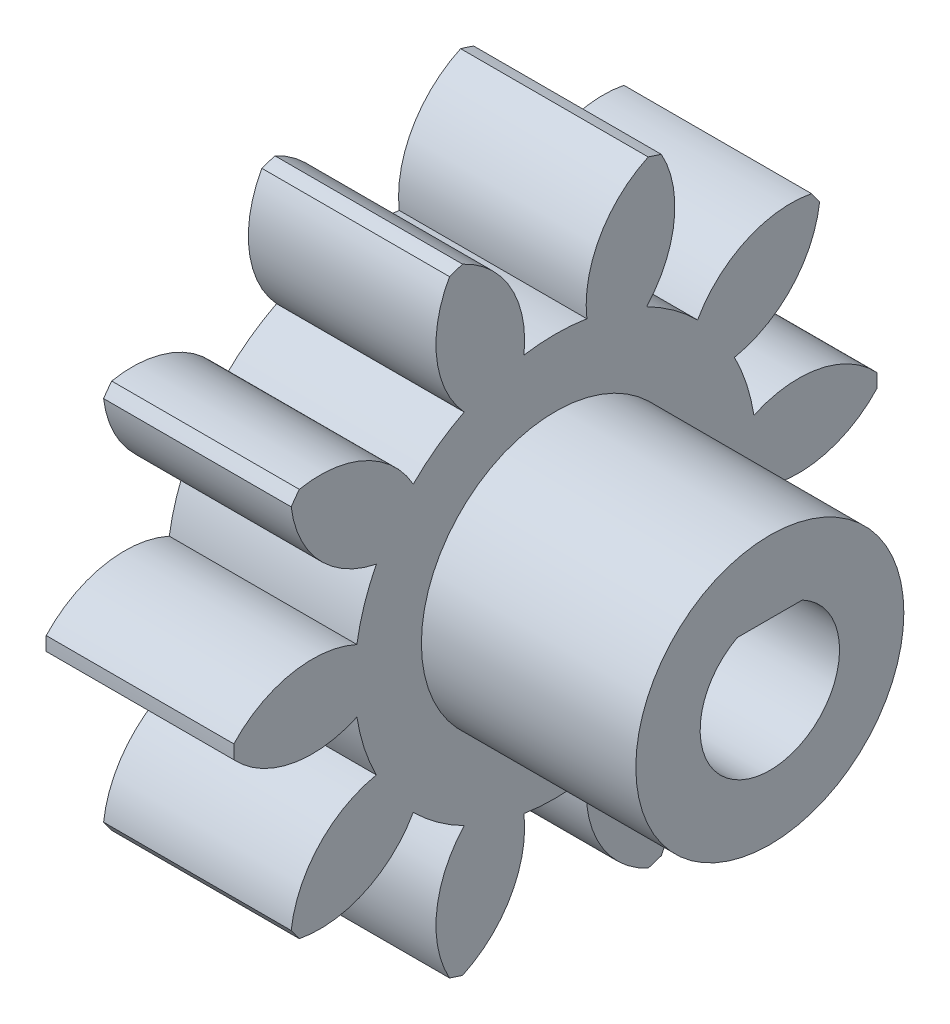
from build123d import *

# Parameters (mm, degrees)
BASPROSKE_W         = 15
BASPROSKE_H         = 12
TOOTHCUT_DEPTH      = 23.649503306
TEETHCUTS_COUNT     = 10
TEETHCUTS_ANGLE     = 324
BORSKE_R            = 0.45
BORE_DEPTH          = 50.0000508
SKETCH1_R           = 0.45
CUT_EXTRUDE1_DEPTH  = 15
CUT_EXTRUDE2_DEPTH  = 8
SKETCH6_R           = 5
BOSS_EXTRUDE1_DEPTH = 8


with BuildPart() as part:
    # BasProSke → Base-Revolve (revolve)
    with BuildSketch(Plane(origin=(0, 0, 0), x_dir=(1, 0, 0), z_dir=(0, 1, 0)), mode=Mode.PRIVATE) as base_revolve_sk:
        with Locations((7.5, 6)):
            Rectangle(BASPROSKE_W, BASPROSKE_H)
    revolve(base_revolve_sk.sketch.rotate(Axis((-10, 0, 0), (1, 0, 0)), 180), axis=Axis((-10, 0, 0), (1, 0, 0)))

    # TooCutSke → ToothCut (cut, through all)
    with BuildSketch(Plane(origin=(0, 0, 0), x_dir=(0, 0, -1), z_dir=(1, 0, 0))):
        with BuildLine():
            ThreePointArc((1.173662691, 7.406586048), (0, 7.499), (-1.173662691, 7.406586048))
            ThreePointArc((-1.173662691, 7.406586048), (-1.668191438, 9.834565786), (-3.497907776, 11.50542856))
            ThreePointArc((-3.497907776, 11.50542856), (0, 12.0254), (3.497907776, 11.50542856))
            ThreePointArc((3.497907776, 11.50542856), (1.668191438, 9.834565786), (1.173662691, 7.406586048))
        make_face()
    toothcut = extrude(amount=TOOTHCUT_DEPTH, mode=Mode.SUBTRACT)

    # TeethCuts: ToothCut ×10 about axis
    teethcuts_axis = Axis((-10, 0, 0), (1, 0, 0))
    for i in range(1, TEETHCUTS_COUNT):
        add(toothcut.rotate(teethcuts_axis, i * TEETHCUTS_ANGLE / (TEETHCUTS_COUNT - 1)), mode=Mode.SUBTRACT)

    # BorSke → Bore (cut, symmetric)
    with BuildSketch(Plane(origin=(0, 0, 0), x_dir=(0, 0, -1), z_dir=(1, 0, 0))):
        with Locations(Location((0, 0, 0), (0, 0, 180))):
            Circle(BORSKE_R)
    extrude(amount=BORE_DEPTH, both=True, mode=Mode.SUBTRACT)

    # Sketch1 → Cut-Extrude1 (cut)
    with BuildSketch(Plane.ZY):
        with BuildLine():
            Line((1.212435565, 2.3), (-1.212435565, 2.3))
            ThreePointArc((-1.212435565, 2.3), (-1.343068786, -2.226244873), (2.6, 0))
            ThreePointArc((2.6, 0), (2.226244873, 1.343068786), (1.212435565, 2.3))
        make_face()
        Circle(SKETCH1_R, mode=Mode.SUBTRACT)
    extrude(amount=-CUT_EXTRUDE1_DEPTH, mode=Mode.SUBTRACT)

    # Sketch5 → Cut-Extrude2 (cut)
    with BuildSketch(Plane.ZY):
        with BuildLine():
            ThreePointArc((-7.406763642, 1.172541409), (-9.849931218, 1.456299749), (-11.997250213, 0.256880001))
            ThreePointArc((-11.997250213, 0.256880001), (-12, 0), (-11.997250213, -0.256880001))
            ThreePointArc((-11.997250213, -0.256880001), (-9.849931218, -1.456299749), (-7.406763642, -1.172541409))
            ThreePointArc((-7.406763642, -1.172541409), (-7.131972816, -2.317318441), (-6.681400207, -3.404980509))
            ThreePointArc((-6.681400207, -3.404980509), (-8.824753264, -4.61147306), (-9.856969584, -6.843986457))
            ThreePointArc((-9.856969584, -6.843986457), (-9.708203932, -7.053423028), (-9.554989032, -7.259627029))
            ThreePointArc((-9.554989032, -7.259627029), (-7.112770233, -6.967815552), (-5.302995112, -5.302192362))
            ThreePointArc((-5.302995112, -5.302192362), (-4.407801607, -6.066818441), (-3.403968986, -6.681915604))
            ThreePointArc((-3.403968986, -6.681915604), (-4.428819506, -8.917819898), (-3.9516616, -11.330682707))
            ThreePointArc((-3.9516616, -11.330682707), (-3.708203932, -11.412678196), (-3.463046803, -11.489443278))
            ThreePointArc((-3.463046803, -11.489443278), (-1.658772773, -9.817862641), (-1.173662691, -7.406586048))
            ThreePointArc((-1.173662691, -7.406586048), (0, -7.499), (1.173662691, -7.406586048))
            ThreePointArc((1.173662691, -7.406586048), (1.658772773, -9.817862641), (3.463046803, -11.489443278))
            ThreePointArc((3.463046803, -11.489443278), (3.708203932, -11.412678196), (3.9516616, -11.330682707))
            ThreePointArc((3.9516616, -11.330682707), (4.428819506, -8.917819898), (3.403968986, -6.681915604))
            ThreePointArc((3.403968986, -6.681915604), (4.407801607, -6.066818441), (5.302995112, -5.302192362))
            ThreePointArc((5.302995112, -5.302192362), (7.112770233, -6.967815552), (9.554989032, -7.259627029))
            ThreePointArc((9.554989032, -7.259627029), (9.708203932, -7.053423028), (9.856969584, -6.843986457))
            ThreePointArc((9.856969584, -6.843986457), (8.824753264, -4.61147306), (6.681400207, -3.404980509))
            ThreePointArc((6.681400207, -3.404980509), (7.131972816, -2.317318441), (7.406763642, -1.172541409))
            ThreePointArc((7.406763642, -1.172541409), (9.849931218, -1.456299749), (11.997250213, -0.256880001))
            ThreePointArc((11.997250213, -0.256880001), (12, 0), (11.997250213, 0.256880001))
            ThreePointArc((11.997250213, 0.256880001), (9.849931218, 1.456299749), (7.406763642, 1.172541409))
            ThreePointArc((7.406763642, 1.172541409), (7.131972816, 2.317318441), (6.681400207, 3.404980509))
            ThreePointArc((6.681400207, 3.404980509), (8.824753264, 4.61147306), (9.856969584, 6.843986457))
            ThreePointArc((9.856969584, 6.843986457), (9.708203932, 7.053423028), (9.554989032, 7.259627029))
            ThreePointArc((9.554989032, 7.259627029), (7.112770233, 6.967815552), (5.302995112, 5.302192362))
            ThreePointArc((5.302995112, 5.302192362), (4.407801607, 6.066818441), (3.403968986, 6.681915604))
            ThreePointArc((3.403968986, 6.681915604), (4.428819506, 8.917819898), (3.9516616, 11.330682707))
            ThreePointArc((3.9516616, 11.330682707), (3.708203932, 11.412678196), (3.463046803, 11.489443278))
            ThreePointArc((3.463046803, 11.489443278), (1.658772773, 9.817862641), (1.173662691, 7.406586048))
            ThreePointArc((1.173662691, 7.406586048), (0, 7.499), (-1.173662691, 7.406586048))
            ThreePointArc((-1.173662691, 7.406586048), (-1.658772773, 9.817862641), (-3.463046803, 11.489443278))
            ThreePointArc((-3.463046803, 11.489443278), (-3.708203932, 11.412678196), (-3.9516616, 11.330682707))
            ThreePointArc((-3.9516616, 11.330682707), (-4.428819506, 8.917819898), (-3.403968986, 6.681915604))
            ThreePointArc((-3.403968986, 6.681915604), (-4.407801607, 6.066818441), (-5.302995112, 5.302192362))
            ThreePointArc((-5.302995112, 5.302192362), (-7.112770233, 6.967815552), (-9.554989032, 7.259627029))
            ThreePointArc((-9.554989032, 7.259627029), (-9.708203932, 7.053423028), (-9.856969584, 6.843986457))
            ThreePointArc((-9.856969584, 6.843986457), (-8.824753264, 4.61147306), (-6.681400207, 3.404980509))
            ThreePointArc((-6.681400207, 3.404980509), (-7.131972816, 2.317318441), (-7.406763642, 1.172541409))
        make_face()
    extrude(amount=-CUT_EXTRUDE2_DEPTH, mode=Mode.SUBTRACT)

    # Sketch6 → Boss-Extrude1 (add)
    with BuildSketch(Plane(origin=(15, 0, 0), x_dir=(0, 0, -1), z_dir=(1, 0, 0))):
        with Locations(Location((0, 0, 0), (0, 0, 180))):
            Circle(SKETCH6_R)
        with BuildLine():
            Line((1.212435565, 2.3), (-1.212435565, 2.3))
            ThreePointArc((-1.212435565, 2.3), (0, -2.6), (1.212435565, 2.3))
        make_face(mode=Mode.SUBTRACT)
    extrude(amount=BOSS_EXTRUDE1_DEPTH)


solid = part.part
